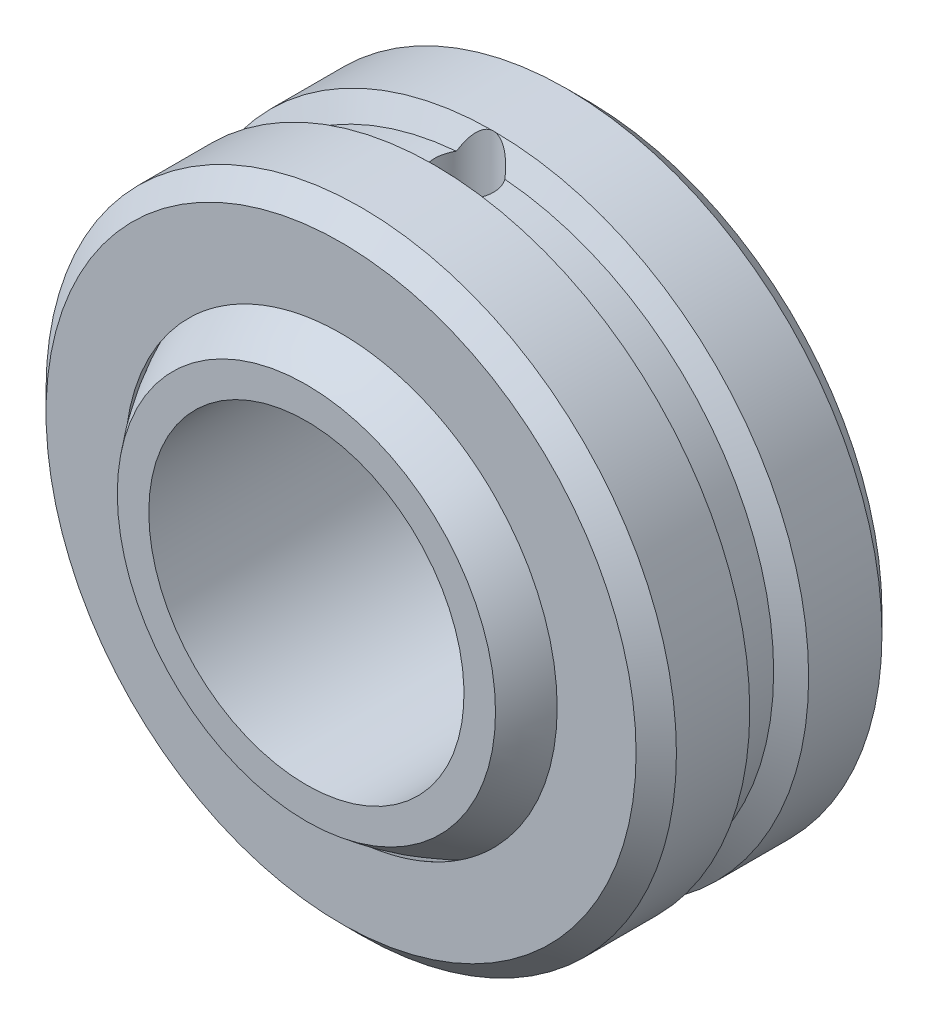
from build123d import *

# Parameters (mm, degrees)
SKETCH1_R               = 12.7
EXTRUDE1_DEPTH          = 4.953
CUT_EXTRUDE1_DEPTH      = 21.565457932
CUT_EXTRUDE1_DEPTH_BACK = 21.565457932
SKETCH4_R               = 6.35
CUT_EXTRUDE2_DEPTH      = 21.565457932
CUT_EXTRUDE2_DEPTH_BACK = 21.565457932
SKETCH5_W               = 1.269587239
SKETCH5_H               = 25.4
CHAMFER1_SIZE           = 0.8128
SKETCH8_R               = 1.186701138
CUT_EXTRUDE3_DEPTH      = 21.565457932


with BuildPart() as part:
    # Sketch1 → Extrude1 (new, symmetric)
    with BuildSketch(Plane.XY):
        Circle(SKETCH1_R)
    extrude(amount=EXTRUDE1_DEPTH, both=True)

    # Sketch2 → Cut-Revolve1 (revolve, cut)
    with BuildSketch(Plane.XY):
        with BuildLine():
            Line((0, 10.017887), (0, -10.017887))
            ThreePointArc((0, -10.017887), (10.017887, 0), (0, 10.017887))
        make_face()
    revolve(axis=Axis((0, 10.017887, 0), (0, 1, 0)), mode=Mode.SUBTRACT)

    # Chamfer1
    chamfer1_edges = [part.edges().sort_by_distance(p)[0] for p in [
        (-12.7, 0, -4.953),
        (-12.7, 0, 4.953),
    ]]
    chamfer(chamfer1_edges, length=CHAMFER1_SIZE)

    # Sketch6 → Cut-Revolve2 (revolve, cut)
    with BuildSketch(Plane(origin=(0, 0, 0), x_dir=(0, 0, -1), z_dir=(1, 0, 0)), mode=Mode.PRIVATE) as cut_revolve2_sk:
        Polygon((-1.186701138, 12.7), (-0.67052825, 11.805962333), (0.67052825, 11.805962333), (1.186701138, 12.7), align=None)
    revolve(cut_revolve2_sk.sketch.rotate(Axis((0, 0, 0), (0, 0, -1)), 90), axis=Axis((0, 0, 0), (0, 0, -1)), mode=Mode.SUBTRACT)

    # Sketch8 → Cut-Extrude3 (cut, through all)
    with BuildSketch(Plane(origin=(0, 0, 0), x_dir=(1, 0, 0), z_dir=(0, 1, 0))):
        with Locations(Location((0, 0, 0), (0, 0, 90))):
            Circle(SKETCH8_R)
    extrude(amount=CUT_EXTRUDE3_DEPTH, mode=Mode.SUBTRACT)


with BuildPart() as body_2:
    # Sketch3 → Revolve1 (revolve)
    with BuildSketch(Plane.XY):
        with BuildLine():
            Line((0, 9.9187), (0, -9.9187))
            ThreePointArc((0, -9.9187), (9.9187, 0), (0, 9.9187))
        make_face()
    revolve(axis=Axis((0, 9.9187, 0), (0, 1, 0)))

    # Sketch4 → Cut-Extrude1 (cut, two sides: drawn at the far end of the back side and taken through both)
    with BuildSketch(Plane.XY.offset(-CUT_EXTRUDE1_DEPTH_BACK)):
        with Locations(Location((0, 0, 0), (0, 0, 180))):
            Circle(SKETCH4_R)
    extrude(amount=CUT_EXTRUDE1_DEPTH + CUT_EXTRUDE1_DEPTH_BACK, mode=Mode.SUBTRACT)

    # Sketch5 → Cut-Extrude2 (cut, two sides: drawn at the far end of the back side and taken through both)
    with BuildSketch(Plane(origin=(0, 0, 0), x_dir=(0, 0, -1), z_dir=(1, 0, 0)).offset(-CUT_EXTRUDE2_DEPTH_BACK)):
        with Locations((-6.98479362, 0)):
            Rectangle(SKETCH5_W, SKETCH5_H)
        with Locations((6.98479362, 0)):
            Rectangle(SKETCH5_W, SKETCH5_H)
    extrude(amount=CUT_EXTRUDE2_DEPTH + CUT_EXTRUDE2_DEPTH_BACK, mode=Mode.SUBTRACT)


solid = Compound([part.part, body_2.part])
